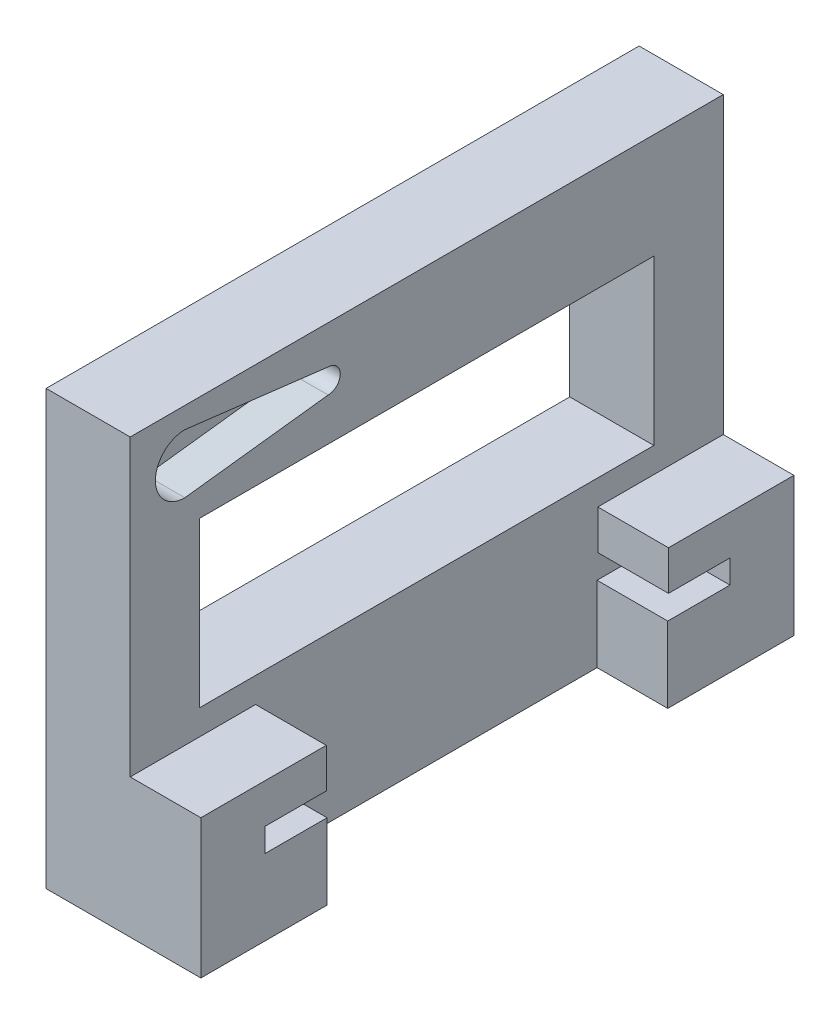
from build123d import *

# Parameters (mm, degrees)
BOSS_EXTRUDE1_DEPTH = 9
SKETCH2_W           = 8.4
SKETCH2_H           = 40.5
CUT_EXTRUDE1_DEPTH  = 40.4
SKETCH3_W           = 18.4
SKETCH3_H           = 70.5
BOSS_EXTRUDE2_DEPTH = 42.5
CUT_EXTRUDE2_DEPTH  = 8.4
SKETCH5_W           = 70.5
SKETCH5_H           = 35
CUT_EXTRUDE3_DEPTH  = 8.4
CUT_EXTRUDE4_DEPTH  = 4.6
SKETCH8_W           = 54
SKETCH8_H           = 19.4972
CUT_EXTRUDE5_DEPTH  = 11


with BuildPart() as part:
    # Sketch1 → Boss-Extrude1 (new body)
    with BuildSketch(Plane(origin=(0, 0, 0), x_dir=(1, 0, 0), z_dir=(0, 1, 0))):
        Polygon((8.4, -15), (8.4, 0), (8.4, 40.5), (8.4, 55.5), (-10, 55.5), (-10, -15), align=None)
    extrude(amount=BOSS_EXTRUDE1_DEPTH)

    # Sketch2 → Cut-Extrude1 (cut)
    with BuildSketch(Plane(origin=(0, 9, 0), x_dir=(1, 0, 0), z_dir=(0, 1, 0))):
        with Locations((4.2, 20.25)):
            Rectangle(SKETCH2_W, SKETCH2_H)
    extrude(amount=-CUT_EXTRUDE1_DEPTH, mode=Mode.SUBTRACT)

    # Sketch3 → Boss-Extrude2 (add)
    with BuildSketch(Plane(origin=(0, 9, 0), x_dir=(1, 0, 0), z_dir=(0, 1, 0))):
        with Locations((-0.8, 20.25)):
            Rectangle(SKETCH3_W, SKETCH3_H)
    extrude(amount=BOSS_EXTRUDE2_DEPTH)

    # Sketch4 → Cut-Extrude2 (cut)
    with BuildSketch(Plane(origin=(8.4, 0, 0), x_dir=(0, 0, -1), z_dir=(1, 0, 0))):
        Polygon((-0.09, 11.8), (-0.09, 44.4), (40.59, 44.4), (40.59, 11.8), (47.9, 11.8), (47.9, 9), (-7.4, 9), (-7.4, 11.8), align=None)
    extrude(amount=-CUT_EXTRUDE2_DEPTH, mode=Mode.SUBTRACT)

    # Sketch5 → Cut-Extrude3 (cut)
    with BuildSketch(Plane(origin=(8.4, 0, 0), x_dir=(0, 0, -1), z_dir=(1, 0, 0))):
        with Locations((20.25, 34)):
            Rectangle(SKETCH5_W, SKETCH5_H)
    extrude(amount=-CUT_EXTRUDE3_DEPTH, mode=Mode.SUBTRACT)

    # Sketch7 → Cut-Extrude4 (cut)
    with BuildSketch(Plane(origin=(0, 0, 0), x_dir=(0, 0, -1), z_dir=(1, 0, 0))):
        with BuildLine():
            Line((-8.5, 49.0028), (8.5259, 46.9454))
            ThreePointArc((8.5259, 46.9454), (9.9713, 45.5), (8.5259, 44.0546))
            Line((8.5259, 44.0546), (-8.5, 41.9972))
            ThreePointArc((-8.5, 41.9972), (-12.0028, 45.5), (-8.5, 49.0028))
        make_face()
    extrude(amount=-CUT_EXTRUDE4_DEPTH, mode=Mode.SUBTRACT)

    # Sketch8 → Cut-Extrude5 (cut, through all)
    with BuildSketch(Plane(origin=(0, 0, 0), x_dir=(0, 0, -1), z_dir=(1, 0, 0))):
        with Locations((20.25, 29.2486)):
            Rectangle(SKETCH8_W, SKETCH8_H)
    extrude(amount=-CUT_EXTRUDE5_DEPTH, mode=Mode.SUBTRACT)


solid = part.part
